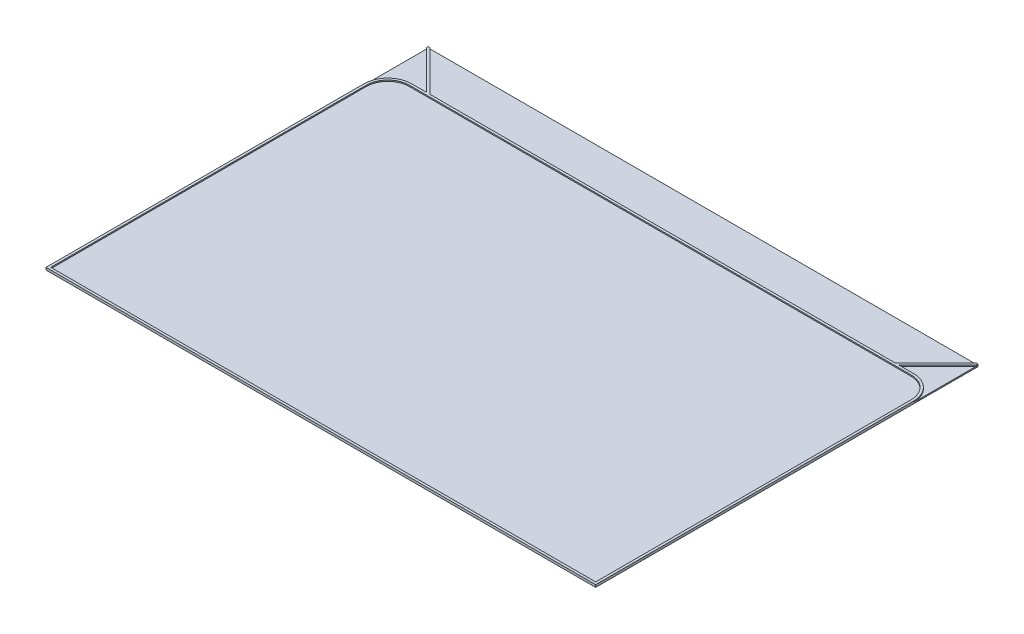
from build123d import *

# Parameters (mm, degrees)
SKETCH1_W           = 230
SKETCH1_H           = 160
BOSS_EXTRUDE1_DEPTH = 0.5
BOSS_EXTRUDE2_DEPTH = 0.5


with BuildPart() as part:
    # Sketch1 → Boss-Extrude1 (new body)
    with BuildSketch(Plane(origin=(0, 0, 0), x_dir=(1, 0, 0), z_dir=(0, 1, 0))):
        Rectangle(SKETCH1_W, SKETCH1_H)
    extrude(amount=BOSS_EXTRUDE1_DEPTH)

    # Sketch2 → Boss-Extrude2 (add)
    with BuildSketch(Plane(origin=(0, 0.5, 0), x_dir=(1, 0, 0), z_dir=(0, 1, 0))):
        with BuildLine():
            Line((-97.32233047, 63.029437252), (-98.736544033, 63.029437252))
            Line((-98.736544033, 63.029437252), (-105, 63.029437252))
            ThreePointArc((-105, 63.029437252), (-112.071067812, 60.100505063), (-115, 53.029437252))
            Line((-115, 53.029437252), (-115, -80))
            Line((-115, -80), (115, -80))
            Line((115, -80), (115, 53.029437252))
            ThreePointArc((115, 53.029437252), (112.071067812, 60.100505063), (105, 63.029437252))
            Line((105, 63.029437252), (98.736544033, 63.029437252))
            Line((98.736544033, 63.029437252), (97.32233047, 63.029437252))
            Line((97.32233047, 63.029437252), (-97.32233047, 63.029437252))
        make_face()
        with BuildLine():
            Line((-105, 62.029437252), (105, 62.029437252))
            ThreePointArc((105, 62.029437252), (111.363961031, 59.393398282), (114, 53.029437252))
            Line((114, 53.029437252), (114, -79))
            Line((114, -79), (-114, -79))
            Line((-114, -79), (-114, 53.029437252))
            ThreePointArc((-114, 53.029437252), (-111.363961031, 59.393398282), (-105, 62.029437252))
        make_face(mode=Mode.SUBTRACT)
        Polygon((-115, 80), (-115, 79.292893219), (-98.736544033, 63.029437252), (-97.32233047, 63.029437252), (-114.292893219, 80), align=None)
        Polygon((114.292893219, 80), (97.32233047, 63.029437252), (98.736544033, 63.029437252), (115, 79.292893219), (115, 80), align=None)
    extrude(amount=BOSS_EXTRUDE2_DEPTH)


solid = part.part
